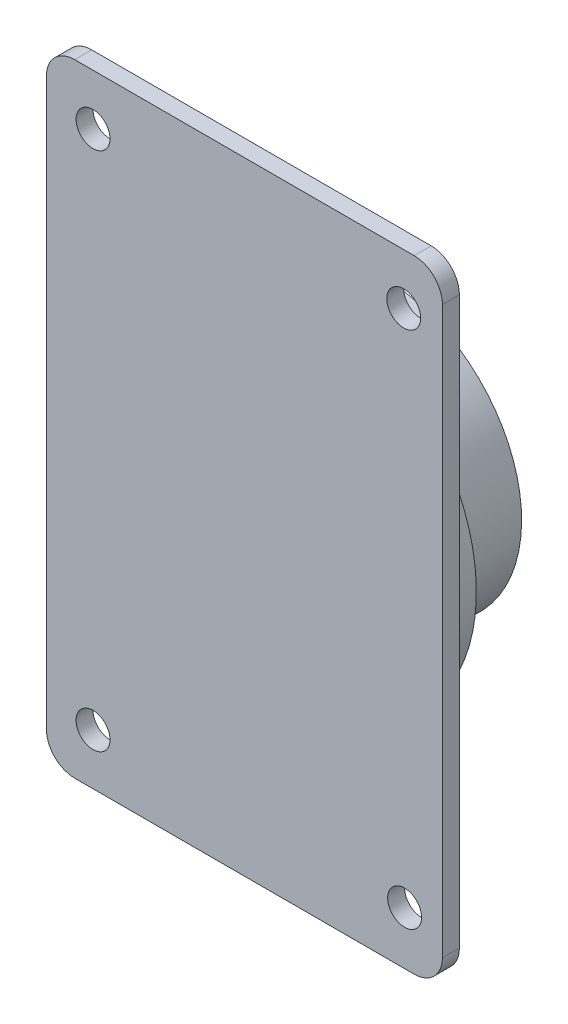
from build123d import *

# Parameters (mm, degrees)
SKETCH3_R             = 25
BOSS_EXTRUDE1_DEPTH   = 15
SKETCH4_R             = 32
BOSS_EXTRUDE2_DEPTH   = 6
BOSS_EXTRUDE3_DEPTH   = 3
FILLET1_R             = 5
FILLET2_R             = 5
SKETCH8_R             = 3
CUT_EXTRUDE1_DEPTH    = 3
BODY_MOVE_COPY1_ANGLE = 120
BODY_MOVE_COPY4_ANGLE = 90


with BuildPart() as part:
    # Sketch3 → Boss-Extrude1 (new body)
    with BuildSketch(Plane(origin=(0, 0, 0), x_dir=(1, 0, 0), z_dir=(0, 1, 0))):
        Circle(SKETCH3_R)
    extrude(amount=-BOSS_EXTRUDE1_DEPTH)

    # Sketch4 → Boss-Extrude2 (add)
    with BuildSketch(Plane.XZ.offset(15)):
        Circle(SKETCH4_R)
    extrude(amount=BOSS_EXTRUDE2_DEPTH)

    # Sketch6 → Boss-Extrude3 (add)
    with BuildSketch(Plane.XZ.offset(21)):
        Polygon((35, 0), (35, -55), (-35, -55), (-35, 55), (35, 55), align=None)
    extrude(amount=BOSS_EXTRUDE3_DEPTH)

    # Fillet1
    fillet1_edges = [part.edges().sort_by_distance(p)[0] for p in [
        (35, -22.5, 55),
    ]]
    fillet(fillet1_edges, radius=FILLET1_R)

    # Fillet2
    fillet2_edges = [part.edges().sort_by_distance(p)[0] for p in [
        (-35, -22.5, 55),
        (-35, -22.5, -55),
        (35, -22.5, -55),
    ]]
    fillet(fillet2_edges, radius=FILLET2_R)

    # Sketch8 → Cut-Extrude1 (cut)
    with BuildSketch(Plane.XZ.offset(24)):
        with Locations((26.758523595, -46)):
            Circle(SKETCH8_R)
        with Locations((-28.158970904, -46)):
            Circle(SKETCH8_R)
        with Locations((26.758523595, 46)):
            Circle(SKETCH8_R)
        with Locations((-28.320886722, 45.663145403)):
            Circle(SKETCH8_R)
    extrude(amount=-CUT_EXTRUDE1_DEPTH, mode=Mode.SUBTRACT)


with BuildPart() as part_1:
    # Body-Move_Copy1: moved
    add(part.part.rotate(Axis((0, 0, 0), (-0.5773502691896252, -0.5773502691896272, 0.5773502691896252)), BODY_MOVE_COPY1_ANGLE))


with BuildPart() as part_2:
    # Body-Move_Copy2: moved
    add(part_1.part.moved(Location((0, 0, -24))))


with BuildPart() as part_3:
    # Body-Move_Copy3: moved
    add(part_2.part.moved(Location((0, 0, 99))))


with BuildPart() as part_4:
    # Body-Move_Copy4: moved
    add(part_3.part.rotate(Axis((0, 0, 0), (0, 0, 1)), BODY_MOVE_COPY4_ANGLE))


solid = part_4.part
